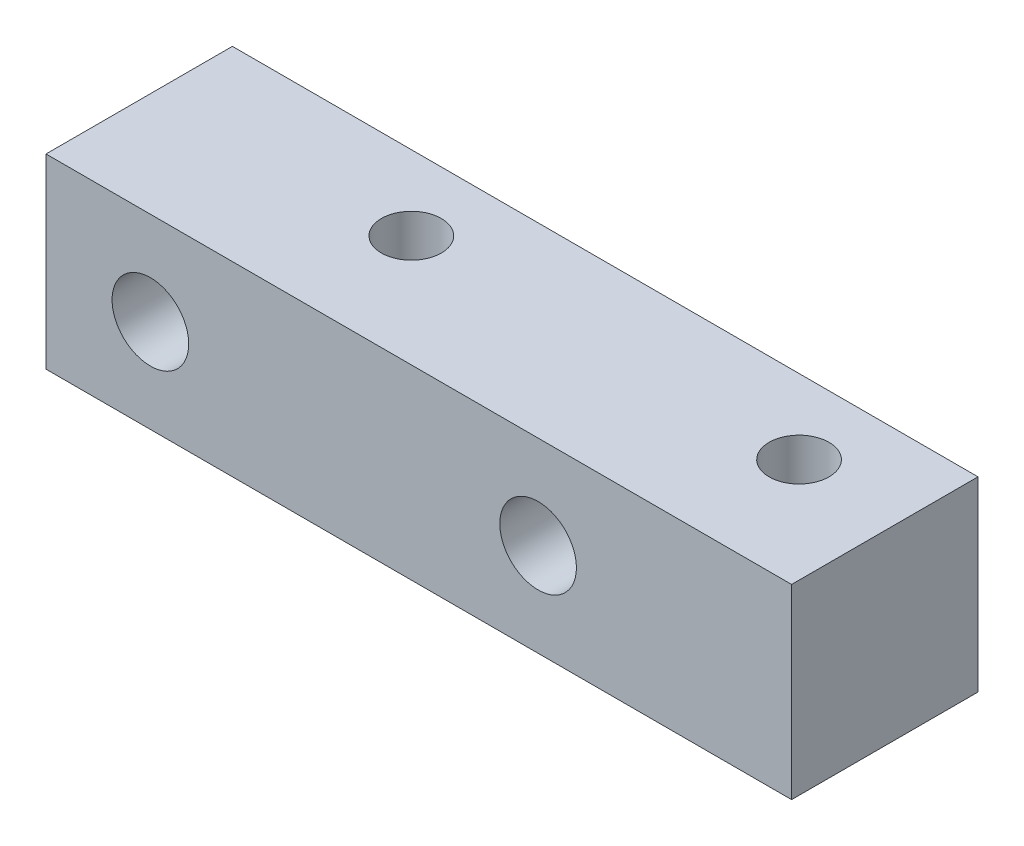
from build123d import *

# Parameters (mm, degrees)
SKETCH2_W              = 63.5
SKETCH2_H              = 15.875
BOSS_EXTRUDE1_DEPTH    = 15.875
F_1_4_20_TAPPED_HOLE_D = 5.1054
F_1_4_CLEARANCE_HOLE_D = 6.5278


with BuildPart() as part:
    # Sketch2 → Boss-Extrude1 (new body)
    with BuildSketch(Plane(origin=(0, 0, 0), x_dir=(1, 0, 0), z_dir=(0, 1, 0))):
        Rectangle(SKETCH2_W, SKETCH2_H)
    extrude(amount=-BOSS_EXTRUDE1_DEPTH)

    # 1/4-20 Tapped Hole (through all)
    with Locations(Plane(origin=(0, 0, 0), x_dir=(1, 0, 0), z_dir=(0, 1, 0))):
        with Locations((-10.16, 1.5875), (22.86, 1.5875)):
            Hole(F_1_4_20_TAPPED_HOLE_D / 2)

    # 1/4 Clearance Hole (through all)
    with Locations(Plane.XY.offset(7.9375)):
        with Locations((-22.86, -7.9375), (10.16, -7.9375)):
            Hole(F_1_4_CLEARANCE_HOLE_D / 2)


solid = part.part
